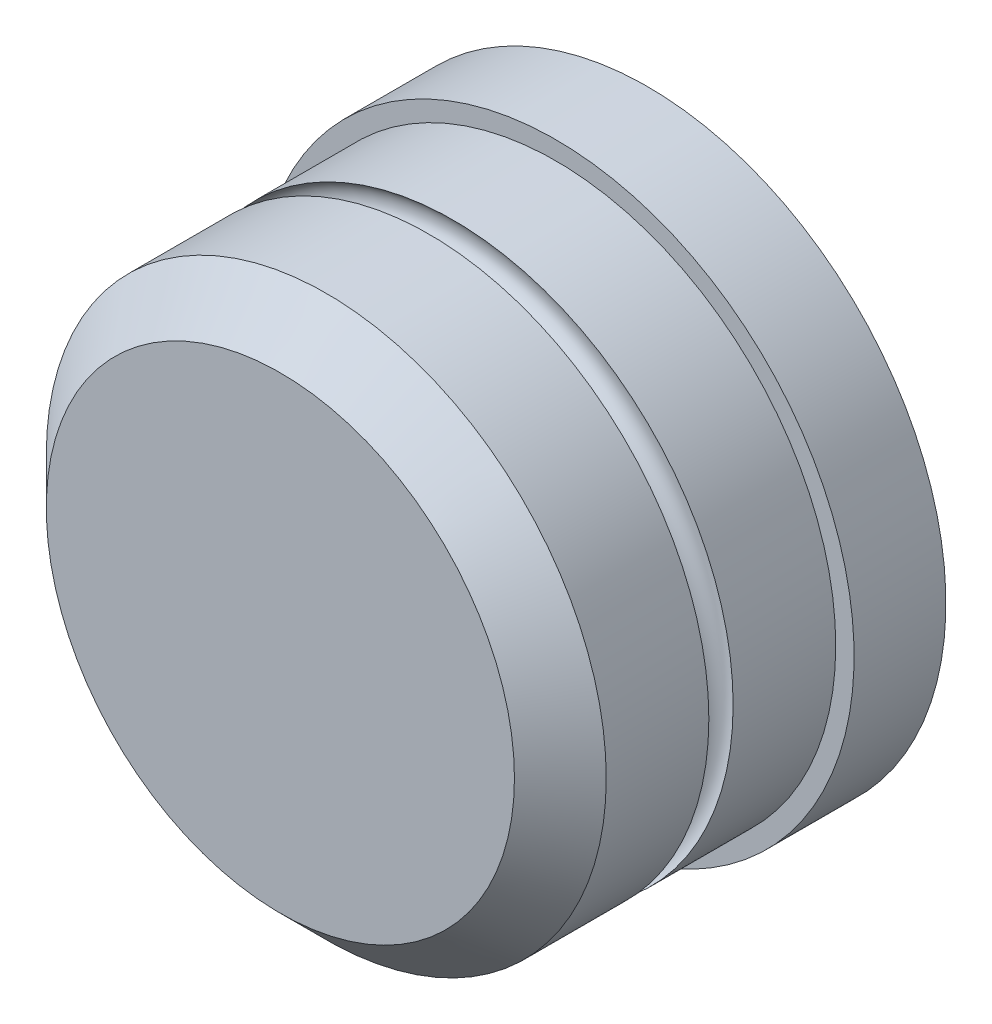
from build123d import *

# Parameters (mm, degrees)
ESQUISSE1_R        = 30.5
BOSS_EXTRU_1_DEPTH = 30
ESQUISSE2_R        = 32.5
BOSS_EXTRU_2_DEPTH = 10
CHANFREIN1_SIZE    = 5
ESQUISSE6_R        = 2


with BuildPart() as part:
    # Esquisse1 → Boss.-Extru.1 (new body)
    with BuildSketch(Plane.XY):
        Circle(ESQUISSE1_R)
    extrude(amount=BOSS_EXTRU_1_DEPTH)

    # Esquisse2 → Boss.-Extru.2 (add)
    with BuildSketch(Plane(origin=(0, 0, 0), x_dir=(-1, 0, 0), z_dir=(0, 0, -1))):
        Circle(ESQUISSE2_R)
    extrude(amount=BOSS_EXTRU_2_DEPTH)

    # Chanfrein1
    chanfrein1_edges = [part.edges().sort_by_distance(p)[0] for p in [
        (-30.5, 0, 30),
    ]]
    chamfer(chanfrein1_edges, length=CHANFREIN1_SIZE)

    # Enlèvement de matière-Balayage1: sweep along a path in Esquisse7
    with BuildLine(Plane.XY.offset(10)) as enl_vement_de_mati_re_balayage1_path:
        CenterArc((0, 0), 26.0040611, 0, 360)
    # Esquisse6 → Enlèvement de matière-Balayage1 (sweep, cut)
    with BuildSketch(Plane(origin=(0, 0, 0), x_dir=(1, 0, 0), z_dir=(0, 1, 0))):
        with Locations((-29, -12.5)):
            Circle(ESQUISSE6_R)
    sweep(path=enl_vement_de_mati_re_balayage1_path.line, mode=Mode.SUBTRACT)


solid = part.part
